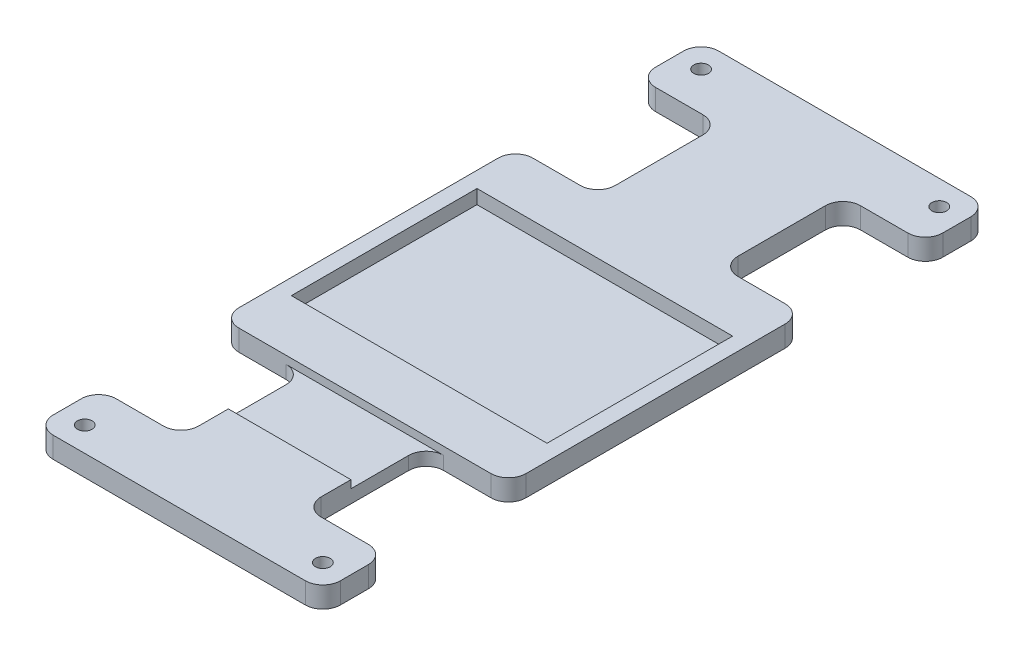
from build123d import *

# Parameters (mm, degrees)
SKETCH1_W           = 85
SKETCH1_H           = 190
BOSS_EXTRUDE1_DEPTH = 6
SKETCH2_W           = 73
SKETCH2_H           = 53
CUT_EXTRUDE1_DEPTH  = 4
SKETCH3_R           = 2.1
CUT_EXTRUDE2_DEPTH  = 9
SKETCH4_W           = 25
SKETCH4_H           = 35
CUT_EXTRUDE3_DEPTH  = 10
SKETCH5_W           = 1.5
SKETCH5_H           = 190
CUT_EXTRUDE4_DEPTH  = 10
SKETCH6_W           = 35
SKETCH6_H           = 21.5
CUT_EXTRUDE5_DEPTH  = 2.25
FILLET1_R           = 5


with BuildPart() as part:
    # Sketch1 → Boss-Extrude1 (new body)
    with BuildSketch(Plane(origin=(0, 0, 0), x_dir=(1, 0, 0), z_dir=(0, 1, 0))):
        Rectangle(SKETCH1_W, SKETCH1_H)
    extrude(amount=BOSS_EXTRUDE1_DEPTH)

    # Sketch2 → Cut-Extrude1 (cut)
    with BuildSketch(Plane(origin=(0, 6, 0), x_dir=(1, 0, 0), z_dir=(0, 1, 0))):
        Rectangle(SKETCH2_W, SKETCH2_H)
    extrude(amount=-CUT_EXTRUDE1_DEPTH, mode=Mode.SUBTRACT)

    # Sketch3 → Cut-Extrude2 (cut)
    with BuildSketch(Plane(origin=(0, 6, 0), x_dir=(1, 0, 0), z_dir=(0, 1, 0))):
        with Locations((34, -88)):
            Circle(SKETCH3_R)
        with Locations((-34, -88)):
            Circle(SKETCH3_R)
        with Locations((-34, 88)):
            Circle(SKETCH3_R)
        with Locations((34, 88)):
            Circle(SKETCH3_R)
    extrude(amount=-CUT_EXTRUDE2_DEPTH, mode=Mode.SUBTRACT)

    # Sketch4 → Cut-Extrude3 (cut)
    with BuildSketch(Plane(origin=(0, 6, 0), x_dir=(1, 0, 0), z_dir=(0, 1, 0))):
        with Locations((-30, 59.5)):
            Rectangle(SKETCH4_W, SKETCH4_H)
        with Locations((-30, -59.5)):
            Rectangle(SKETCH4_W, SKETCH4_H)
        with Locations((30, -59.5)):
            Rectangle(SKETCH4_W, SKETCH4_H)
        with Locations((30, 59.5)):
            Rectangle(SKETCH4_W, SKETCH4_H)
    extrude(amount=-CUT_EXTRUDE3_DEPTH, mode=Mode.SUBTRACT)

    # Sketch5 → Cut-Extrude4 (cut)
    with BuildSketch(Plane(origin=(0, 6, 0), x_dir=(1, 0, 0), z_dir=(0, 1, 0))):
        with Locations((-41.75, 0)):
            Rectangle(SKETCH5_W, SKETCH5_H)
        with Locations((41.75, 0)):
            Rectangle(SKETCH5_W, SKETCH5_H)
    extrude(amount=-CUT_EXTRUDE4_DEPTH, mode=Mode.SUBTRACT)

    # Sketch6 → Cut-Extrude5 (cut)
    with BuildSketch(Plane(origin=(0, 6, 0), x_dir=(1, 0, 0), z_dir=(0, 1, 0))):
        with Locations((0, -52.75)):
            Rectangle(SKETCH6_W, SKETCH6_H)
    extrude(amount=-CUT_EXTRUDE5_DEPTH, mode=Mode.SUBTRACT)

    # Fillet1
    fillet1_edges = [part.edges().sort_by_distance(p)[0] for p in [
        (41, 3, -77),
        (-41, 3, 77),
        (-41, 3, -42),
        (-41, 3, 42),
        (-41, 3, -95),
        (-41, 3, -77),
        (-41, 3, 95),
        (41, 3, 42),
        (41, 3, -42),
        (41, 3, 95),
        (41, 3, 77),
        (41, 3, -95),
        (17.5, 3, -42),
        (17.5, 3, -77),
        (-17.5, 1.875, 42),
        (-17.5, 3, 77),
        (17.5, 3, 77),
        (17.5, 1.875, 42),
        (-17.5, 3, -77),
        (-17.5, 3, -42),
    ]]
    fillet(fillet1_edges, radius=FILLET1_R)


solid = part.part
